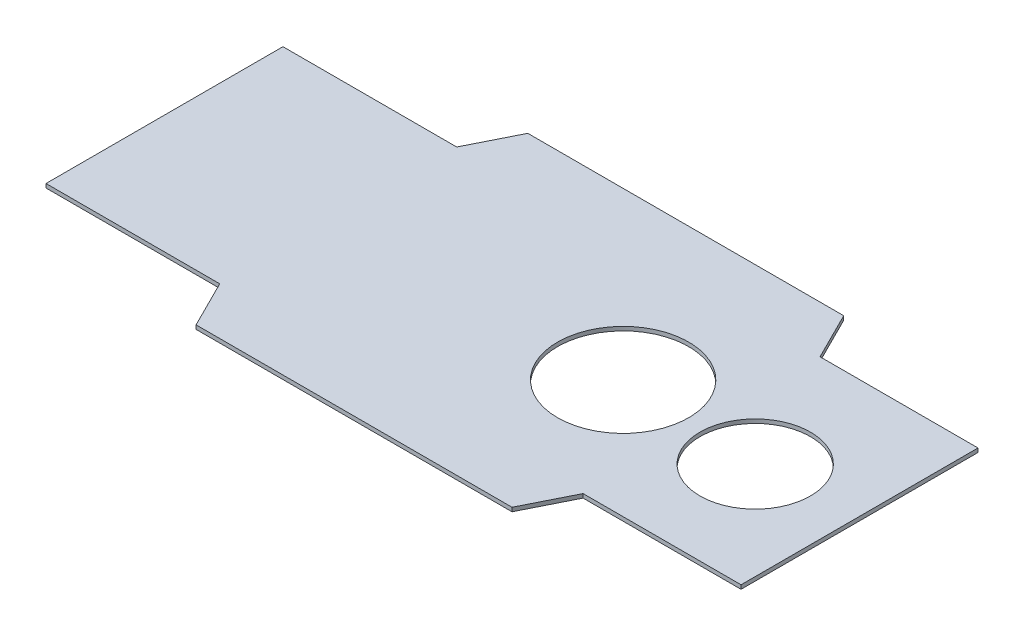
from build123d import *

# Parameters (mm, degrees)
BOSS_EXTRUDE1_DEPTH = 1.5875
SKETCH7_R           = 52.705
SKETCH7_R_2         = 44.45
CUT_EXTRUDE1_DEPTH  = 20.32


with BuildPart() as part:
    # Sketch3 → Boss-Extrude1 (new body, symmetric)
    with BuildSketch(Plane(origin=(0, 0, 0), x_dir=(1, 0, 0), z_dir=(0, 1, 0))):
        Polygon((-279.4, 95.25), (-139.7, 95.25), (-120.65, 133.35), (133.35, 133.35), (152.4, 95.25), (279.4, 95.25), (279.4, -95.25), (152.4, -95.25), (133.35, -133.35), (-120.65, -133.35), (-139.7, -95.25), (-279.4, -95.25), align=None)
    extrude(amount=BOSS_EXTRUDE1_DEPTH, both=True)

    # Sketch7 → Cut-Extrude1 (cut)
    with BuildSketch(Plane(origin=(0, 1.5875, 0), x_dir=(1, 0, 0), z_dir=(0, 1, 0))):
        with Locations((89.349601684, 0)):
            Circle(SKETCH7_R)
        with Locations((201.029841253, -5.49358251)):
            Circle(SKETCH7_R_2)
    extrude(amount=-CUT_EXTRUDE1_DEPTH, mode=Mode.SUBTRACT)


solid = part.part
